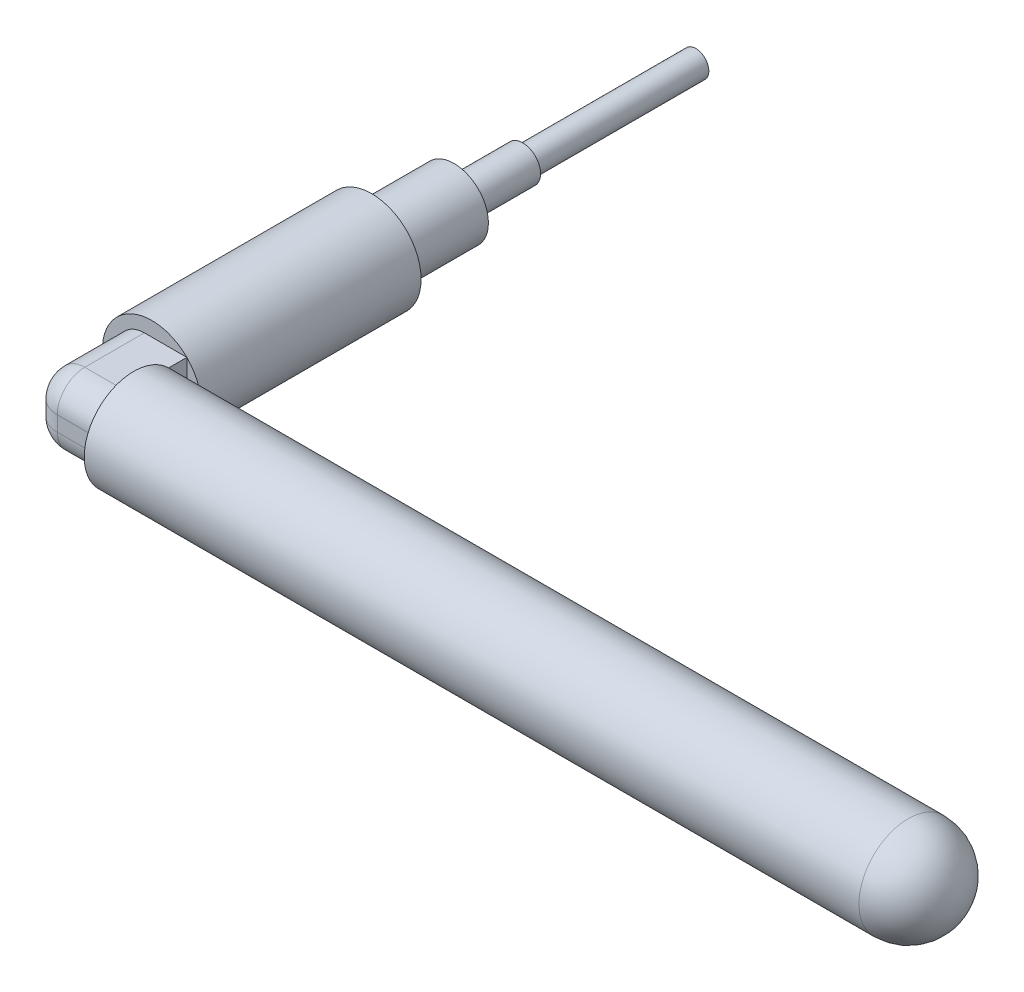
from build123d import *

# Parameters (mm, degrees)
SKETCH1_R           = 4.572
BOSS_EXTRUDE1_DEPTH = 20.32
SKETCH2_R           = 3.175
BOSS_EXTRUDE2_DEPTH = 7.62
SKETCH3_R           = 1.651
BOSS_EXTRUDE3_DEPTH = 6.35
SKETCH4_R           = 1.2065
BOSS_EXTRUDE4_DEPTH = 16.002
SKETCH8_W           = 6.465784408
SKETCH8_H           = 6.465784408
BOSS_EXTRUDE5_DEPTH = 8.0518
SKETCH10_R          = 4.572
BOSS_EXTRUDE6_DEPTH = 71.628
DOME4_FACE_RADIUS   = 4.572
DOME4_HEIGHT        = 4.572
FILLET1_R           = 2.54


with BuildPart() as part:
    # Sketch1 → Boss-Extrude1 (new body)
    with BuildSketch(Plane.XY):
        Circle(SKETCH1_R)
    extrude(amount=BOSS_EXTRUDE1_DEPTH)

    # Sketch2 → Boss-Extrude2 (add)
    with BuildSketch(Plane(origin=(0, 0, 0), x_dir=(-1, 0, 0), z_dir=(0, 0, -1))):
        Circle(SKETCH2_R)
    extrude(amount=BOSS_EXTRUDE2_DEPTH)

    # Sketch3 → Boss-Extrude3 (add)
    with BuildSketch(Plane(origin=(0, 0, -7.62), x_dir=(-1, 0, 0), z_dir=(0, 0, -1))):
        Circle(SKETCH3_R)
    extrude(amount=BOSS_EXTRUDE3_DEPTH)

    # Sketch4 → Boss-Extrude4 (add)
    with BuildSketch(Plane(origin=(0, 0, -13.97), x_dir=(-1, 0, 0), z_dir=(0, 0, -1))):
        Circle(SKETCH4_R)
    extrude(amount=BOSS_EXTRUDE4_DEPTH)

    # Sketch8 → Boss-Extrude5 (add)
    with BuildSketch(Plane.XY.offset(20.32)):
        Rectangle(SKETCH8_W, SKETCH8_H)
    extrude(amount=BOSS_EXTRUDE5_DEPTH)

    # Sketch10 → Boss-Extrude6 (add)
    with BuildSketch(Plane(origin=(3.232892204, 0, 0), x_dir=(0, 0, -1), z_dir=(1, 0, 0))):
        with Locations((-25.2349, 0)):
            Circle(SKETCH10_R)
    extrude(amount=BOSS_EXTRUDE6_DEPTH)

    # Dome4: a dome of height H over a round flat face of radius A is a cap of a sphere of radius (A * A + H * H) / (2 * H)
    dome4_r = (DOME4_FACE_RADIUS * DOME4_FACE_RADIUS + DOME4_HEIGHT * DOME4_HEIGHT) / (2 * DOME4_HEIGHT)
    dome4_base = Plane((74.860892204, 0, 25.2349), z_dir=(1, 0, 0))
    with Locations(dome4_base.offset(DOME4_HEIGHT - dome4_r)):
        dome4_ball = Sphere(dome4_r, mode=Mode.PRIVATE)
    add(split(dome4_ball, bisect_by=dome4_base, keep=Keep.TOP, mode=Mode.PRIVATE))

    # Fillet1
    fillet1_edges = [part.edges().sort_by_distance(p)[0] for p in [
        (-3.232892204, 3.232892204, 24.3459),
        (-3.232892204, -3.232892204, 24.3459),
        (0, 3.232892204, 28.3718),
        (-3.232892204, 0, 28.3718),
        (0, -3.232892204, 28.3718),
    ]]
    fillet(fillet1_edges, radius=FILLET1_R)


solid = part.part
